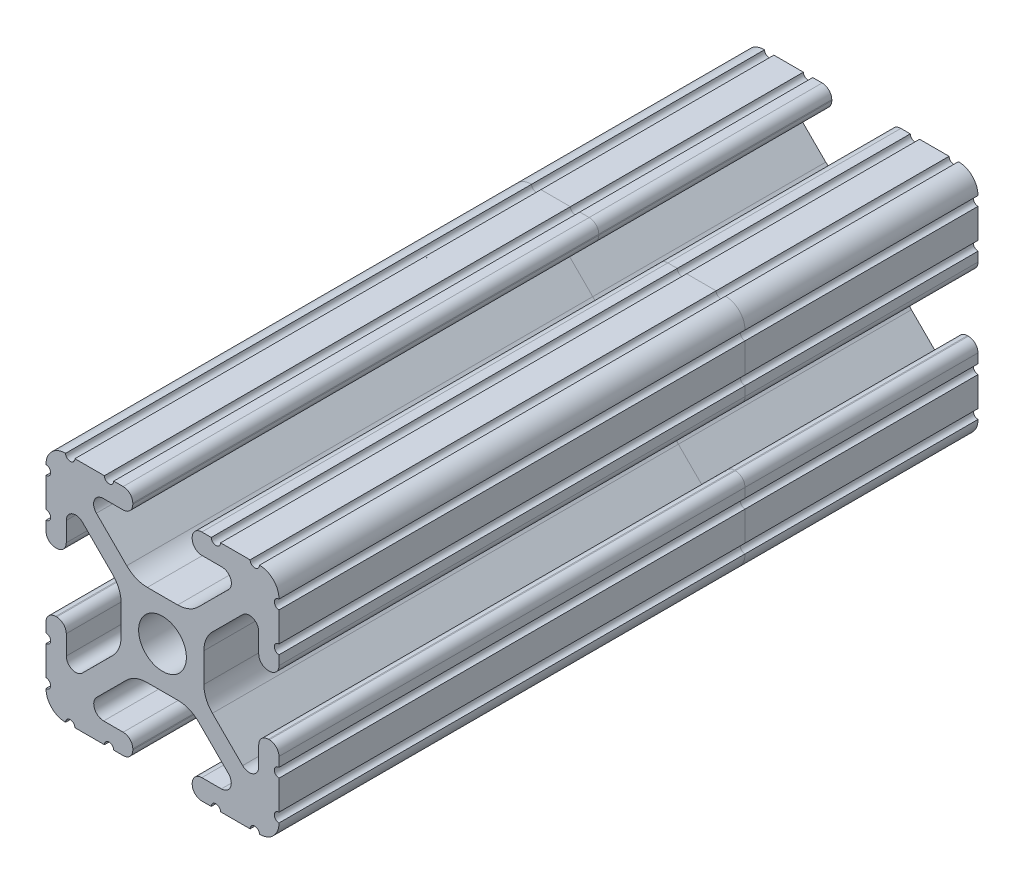
from build123d import *

# Parameters (mm, degrees)
SKETCH1_R           = 2.6035
BOSS_EXTRUDE1_DEPTH = 38.1


with BuildPart() as part:
    # Sketch1 → Boss-Extrude1 (new body, symmetric)
    with BuildSketch(Plane.XY):
        with BuildLine():
            Line((-7.179650497, -8.645192506), (-3.952270251, -5.423690499))
            ThreePointArc((-3.952270251, -5.423690499), (-2.922936451, -4.736929036), (-1.709253557, -4.4958))
            Line((-1.709253557, -4.4958), (1.709253557, -4.4958))
            ThreePointArc((1.709253557, -4.4958), (2.922936451, -4.736929036), (3.952270251, -5.423690499))
            Line((3.952270251, -5.423690499), (7.179650497, -8.645192506))
            ThreePointArc((7.179650497, -8.645192506), (7.41473083, -9.822813117), (6.416408329, -10.4902))
            Line((6.416408329, -10.4902), (4.287512407, -10.4902))
            ThreePointArc((4.287512407, -10.4902), (3.54574862, -10.79744862), (3.2385, -11.539212407))
            Line((3.2385, -11.539212407), (3.2385, -11.650987593))
            ThreePointArc((3.2385, -11.650987593), (3.54574862, -12.39275138), (4.287512407, -12.7))
            Line((4.287512407, -12.7), (5.317126718, -12.7))
            ThreePointArc((5.317126718, -12.7), (5.825126718, -12.192), (6.333126718, -12.7))
            Line((6.333126718, -12.7), (9.550443118, -12.7))
            ThreePointArc((9.550443118, -12.7), (10.058366869, -12.192000006), (10.566443095, -12.699847501))
            ThreePointArc((10.566443095, -12.699847501), (12.082537762, -12.08250727), (12.699846982, -10.566399977))
            ThreePointArc((12.699846982, -10.566399977), (12.192000006, -10.058323491), (12.7, -9.5504))
            Line((12.7, -9.5504), (12.7, -6.3330836))
            ThreePointArc((12.7, -6.3330836), (12.192, -5.8250836), (12.7, -5.3170836))
            Line((12.7, -5.3170836), (12.7, -4.287469289))
            ThreePointArc((12.7, -4.287469289), (12.39275138, -3.545705502), (11.650987593, -3.238456882))
            Line((11.650987593, -3.238456882), (11.539212407, -3.238456882))
            ThreePointArc((11.539212407, -3.238456882), (10.79744862, -3.545705502), (10.4902, -4.287469289))
            Line((10.4902, -4.287469289), (10.4902, -6.402089023))
            ThreePointArc((10.4902, -6.402089023), (9.856505071, -7.351067942), (8.737131347, -7.129408934))
            Line((8.737131347, -7.129408934), (5.441005833, -3.840816462))
            ThreePointArc((5.441005833, -3.840816462), (4.750877967, -2.809883091), (4.5085, -1.593185507))
            Line((4.5085, -1.593185507), (4.5085, 1.593185507))
            ThreePointArc((4.5085, 1.593185507), (4.750877967, 2.809883091), (5.441005833, 3.840816462))
            Line((5.441005833, 3.840816462), (8.737131347, 7.129408934))
            ThreePointArc((8.737131347, 7.129408934), (9.856505071, 7.351067942), (10.4902, 6.402089023))
            Line((10.4902, 6.402089023), (10.4902, 4.287469289))
            ThreePointArc((10.4902, 4.287469289), (10.79744862, 3.545705502), (11.539212407, 3.238456882))
            Line((11.539212407, 3.238456882), (11.650987593, 3.238456882))
            ThreePointArc((11.650987593, 3.238456882), (12.39275138, 3.545705502), (12.7, 4.287469289))
            Line((12.7, 4.287469289), (12.7, 5.3170836))
            ThreePointArc((12.7, 5.3170836), (12.192, 5.8250836), (12.7, 6.3330836))
            Line((12.7, 6.3330836), (12.7, 9.5504))
            ThreePointArc((12.7, 9.5504), (12.192000006, 10.058323491), (12.699846982, 10.566399977))
            ThreePointArc((12.699846982, 10.566399977), (12.082537762, 12.08250727), (10.566443095, 12.699847501))
            ThreePointArc((10.566443095, 12.699847501), (10.058366869, 12.192000006), (9.550443118, 12.7))
            Line((9.550443118, 12.7), (6.333126718, 12.7))
            ThreePointArc((6.333126718, 12.7), (5.825126718, 12.192), (5.317126718, 12.7))
            Line((5.317126718, 12.7), (4.287512407, 12.7))
            ThreePointArc((4.287512407, 12.7), (3.54574862, 12.39275138), (3.2385, 11.650987593))
            Line((3.2385, 11.650987593), (3.2385, 11.539212407))
            ThreePointArc((3.2385, 11.539212407), (3.54574862, 10.79744862), (4.287512407, 10.4902))
            Line((4.287512407, 10.4902), (6.476788598, 10.4902))
            ThreePointArc((6.476788598, 10.4902), (7.432222385, 9.85140422), (7.207036008, 8.724370562))
            Line((7.207036008, 8.724370562), (3.898272566, 5.423169045))
            ThreePointArc((3.898272566, 5.423169045), (2.869120213, 4.736787962), (1.655778399, 4.4958))
            Line((1.655778399, 4.4958), (-1.655778399, 4.4958))
            ThreePointArc((-1.655778399, 4.4958), (-2.869120213, 4.736787962), (-3.898272566, 5.423169045))
            Line((-3.898272566, 5.423169045), (-7.207036008, 8.724370562))
            ThreePointArc((-7.207036008, 8.724370562), (-7.432222385, 9.85140422), (-6.476788598, 10.4902))
            Line((-6.476788598, 10.4902), (-4.287512407, 10.4902))
            ThreePointArc((-4.287512407, 10.4902), (-3.54574862, 10.79744862), (-3.2385, 11.539212407))
            Line((-3.2385, 11.539212407), (-3.2385, 11.650987593))
            ThreePointArc((-3.2385, 11.650987593), (-3.54574862, 12.39275138), (-4.287512407, 12.7))
            Line((-4.287512407, 12.7), (-5.317126718, 12.7))
            ThreePointArc((-5.317126718, 12.7), (-5.825126718, 12.192), (-6.333126718, 12.7))
            Line((-6.333126718, 12.7), (-9.550443118, 12.7))
            ThreePointArc((-9.550443118, 12.7), (-10.058366869, 12.192000006), (-10.566443095, 12.699847501))
            ThreePointArc((-10.566443095, 12.699847501), (-12.082537762, 12.08250727), (-12.699846982, 10.566399977))
            ThreePointArc((-12.699846982, 10.566399977), (-12.192000006, 10.058323491), (-12.7, 9.5504))
            Line((-12.7, 9.5504), (-12.7, 6.3330836))
            ThreePointArc((-12.7, 6.3330836), (-12.192, 5.8250836), (-12.7, 5.3170836))
            Line((-12.7, 5.3170836), (-12.7, 4.287469289))
            ThreePointArc((-12.7, 4.287469289), (-12.39275138, 3.545705502), (-11.650987593, 3.238456882))
            Line((-11.650987593, 3.238456882), (-11.539212407, 3.238456882))
            ThreePointArc((-11.539212407, 3.238456882), (-10.79744862, 3.545705502), (-10.4902, 4.287469289))
            Line((-10.4902, 4.287469289), (-10.4902, 6.402089023))
            ThreePointArc((-10.4902, 6.402089023), (-9.856505071, 7.351067942), (-8.737131347, 7.129408934))
            Line((-8.737131347, 7.129408934), (-5.441005833, 3.840816462))
            ThreePointArc((-5.441005833, 3.840816462), (-4.750877967, 2.809883091), (-4.5085, 1.593185507))
            Line((-4.5085, 1.593185507), (-4.5085, -1.593185507))
            ThreePointArc((-4.5085, -1.593185507), (-4.750877967, -2.809883091), (-5.441005833, -3.840816462))
            Line((-5.441005833, -3.840816462), (-8.737131347, -7.129408934))
            ThreePointArc((-8.737131347, -7.129408934), (-9.856505071, -7.351067942), (-10.4902, -6.402089023))
            Line((-10.4902, -6.402089023), (-10.4902, -4.287469289))
            ThreePointArc((-10.4902, -4.287469289), (-10.79744862, -3.545705502), (-11.539212407, -3.238456882))
            Line((-11.539212407, -3.238456882), (-11.650987593, -3.238456882))
            ThreePointArc((-11.650987593, -3.238456882), (-12.39275138, -3.545705502), (-12.7, -4.287469289))
            Line((-12.7, -4.287469289), (-12.7, -5.3170836))
            ThreePointArc((-12.7, -5.3170836), (-12.192, -5.8250836), (-12.7, -6.3330836))
            Line((-12.7, -6.3330836), (-12.7, -9.5504))
            ThreePointArc((-12.7, -9.5504), (-12.192000006, -10.058323491), (-12.699846982, -10.566399977))
            ThreePointArc((-12.699846982, -10.566399977), (-12.082537762, -12.08250727), (-10.566443095, -12.699847501))
            ThreePointArc((-10.566443095, -12.699847501), (-10.058366869, -12.192000006), (-9.550443118, -12.7))
            Line((-9.550443118, -12.7), (-6.333126718, -12.7))
            ThreePointArc((-6.333126718, -12.7), (-5.825126718, -12.192), (-5.317126718, -12.7))
            Line((-5.317126718, -12.7), (-4.287512407, -12.7))
            ThreePointArc((-4.287512407, -12.7), (-3.54574862, -12.39275138), (-3.2385, -11.650987593))
            Line((-3.2385, -11.650987593), (-3.2385, -11.539212407))
            ThreePointArc((-3.2385, -11.539212407), (-3.54574862, -10.79744862), (-4.287512407, -10.4902))
            Line((-4.287512407, -10.4902), (-6.416408329, -10.4902))
            ThreePointArc((-6.416408329, -10.4902), (-7.41473083, -9.822813117), (-7.179650497, -8.645192506))
        make_face()
        Circle(SKETCH1_R, mode=Mode.SUBTRACT)
    extrude(amount=BOSS_EXTRUDE1_DEPTH, both=True)


with BuildPart() as body_2:
    # Split1: the piece on the far side of the plane
    add(part.part)
    split(bisect_by=Plane(origin=(0, 0, -12.7), x_dir=(-1, 0, 0), z_dir=(0, 0, -1)), keep=Keep.BOTTOM)


with BuildPart() as part_1:
    add(part.part)

    # Split1
    split(bisect_by=Plane(origin=(0, 0, -12.7), x_dir=(-1, 0, 0), z_dir=(0, 0, -1)), keep=Keep.TOP)


solid = Compound([body_2.part, part_1.part])
